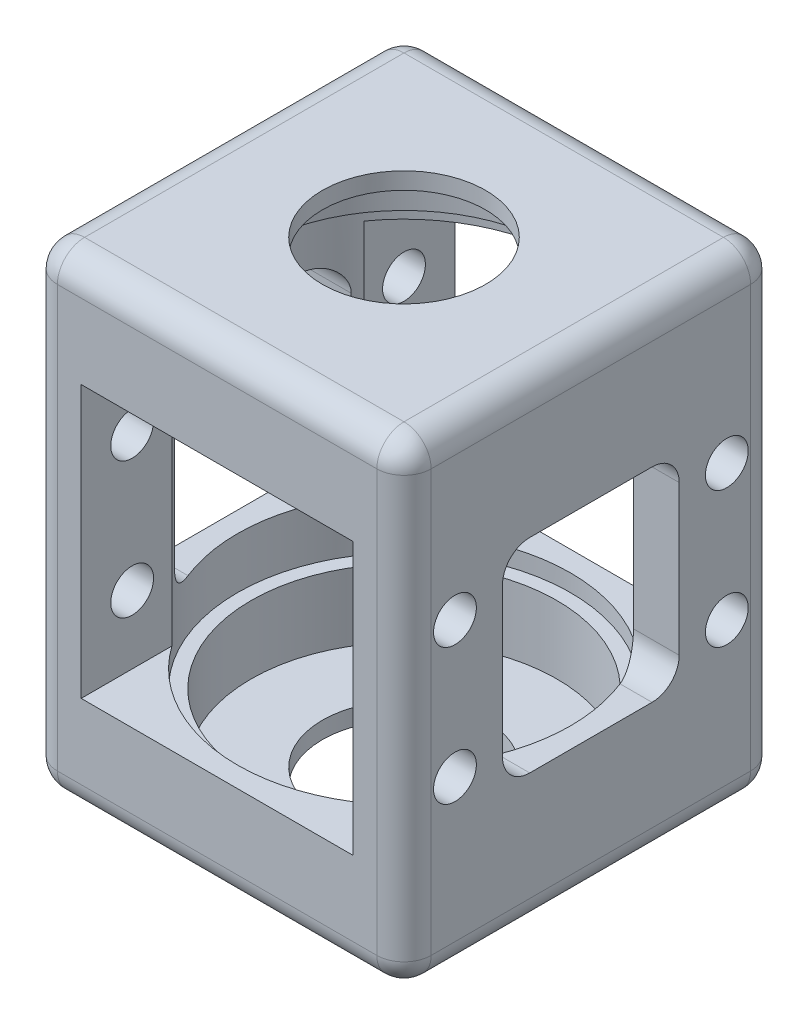
from build123d import *

# Parameters (mm, degrees)
SKETCH1_W               = 34.925
SKETCH1_H               = 34.925
SKETCH1_R               = 7.62
BOSS_EXTRUDE1_DEPTH     = 44.45
SKETCH2_W               = 25.4
SKETCH2_H               = 25.4
CUT_EXTRUDE1_DEPTH      = 44.45
SKETCH3_R               = 15.5575
CUT_EXTRUDE2_DEPTH      = 27.0002
CUT_EXTRUDE2_DEPTH_BACK = 1.6002
SKETCH4_R               = 14.2875
CUT_EXTRUDE3_DEPTH      = 34.9504
CUT_EXTRUDE3_DEPTH_BACK = 6.35
SKETCH5_W               = 16.51
SKETCH5_H               = 19.05
CUT_EXTRUDE4_DEPTH      = 228.6
SKETCH6_R               = 2
CUT_EXTRUDE5_DEPTH      = 228.6
FILLET1_R               = 2.54


with BuildPart() as part:
    # Sketch1 → Boss-Extrude1 (new body)
    with BuildSketch(Plane(origin=(0, 0, 0), x_dir=(1, 0, 0), z_dir=(0, 1, 0))):
        Rectangle(SKETCH1_W, SKETCH1_H)
        Circle(SKETCH1_R, mode=Mode.SUBTRACT)
    extrude(amount=BOSS_EXTRUDE1_DEPTH)

    # Sketch2 → Cut-Extrude1 (cut)
    with BuildSketch(Plane.XY.offset(17.4625)):
        with Locations((0, 22.225)):
            Rectangle(SKETCH2_W, SKETCH2_H)
    extrude(amount=-CUT_EXTRUDE1_DEPTH, mode=Mode.SUBTRACT)

    # Sketch3 → Cut-Extrude2 (cut, two sides)
    with BuildSketch(Plane(origin=(0, 9.525, 0), x_dir=(1, 0, 0), z_dir=(0, 1, 0))) as cut_extrude2_sk:
        Circle(SKETCH3_R)
    extrude(amount=CUT_EXTRUDE2_DEPTH, mode=Mode.SUBTRACT)
    extrude(cut_extrude2_sk.sketch, amount=-CUT_EXTRUDE2_DEPTH_BACK, mode=Mode.SUBTRACT)

    # Sketch4 → Cut-Extrude3 (cut, two sides)
    with BuildSketch(Plane(origin=(0, 7.9248, 0), x_dir=(1, 0, 0), z_dir=(0, 1, 0))) as cut_extrude3_sk:
        Circle(SKETCH4_R)
    extrude(amount=CUT_EXTRUDE3_DEPTH, mode=Mode.SUBTRACT)
    extrude(cut_extrude3_sk.sketch, amount=-CUT_EXTRUDE3_DEPTH_BACK, mode=Mode.SUBTRACT)

    # Sketch5 → Cut-Extrude4 (cut)
    with BuildSketch(Plane.ZY.offset(17.4625)):
        with Locations((0, 22.225)):
            Rectangle(SKETCH5_W, SKETCH5_H)
    extrude(amount=-CUT_EXTRUDE4_DEPTH, mode=Mode.SUBTRACT)

    # Sketch6 → Cut-Extrude5 (cut)
    with BuildSketch(Plane.ZY.offset(17.4625)):
        with Locations((-12.7, 28.575)):
            Circle(SKETCH6_R)
        with Locations((-12.7, 15.875)):
            Circle(SKETCH6_R)
        with Locations((12.7, 15.875)):
            Circle(SKETCH6_R)
        with Locations((12.7, 28.575)):
            Circle(SKETCH6_R)
    extrude(amount=-CUT_EXTRUDE5_DEPTH, mode=Mode.SUBTRACT)

    # Fillet1
    fillet1_edges = [part.edges().sort_by_distance(p)[0] for p in [
        (-17.4625, 44.45, 0),
        (0, 44.45, 17.4625),
        (17.4625, 44.45, 0),
        (0, 0, 17.4625),
        (-17.4625, 0, 0),
        (0, 0, -17.4625),
        (17.4625, 0, 0),
        (15.324632691, 31.75, 8.255),
        (-15.324632691, 31.75, 8.255),
        (15.324632691, 12.7, 8.255),
        (17.4625, 22.225, 17.4625),
        (15.324632691, 12.7, -8.255),
        (15.324632691, 31.75, -8.255),
        (-17.4625, 22.225, 17.4625),
        (-17.4625, 22.225, -17.4625),
        (-15.324632691, 12.7, 8.255),
        (-15.324632691, 12.7, -8.255),
        (-15.324632691, 31.75, -8.255),
        (17.4625, 22.225, -17.4625),
        (0, 44.45, -17.4625),
    ]]
    fillet(fillet1_edges, radius=FILLET1_R)


solid = part.part
